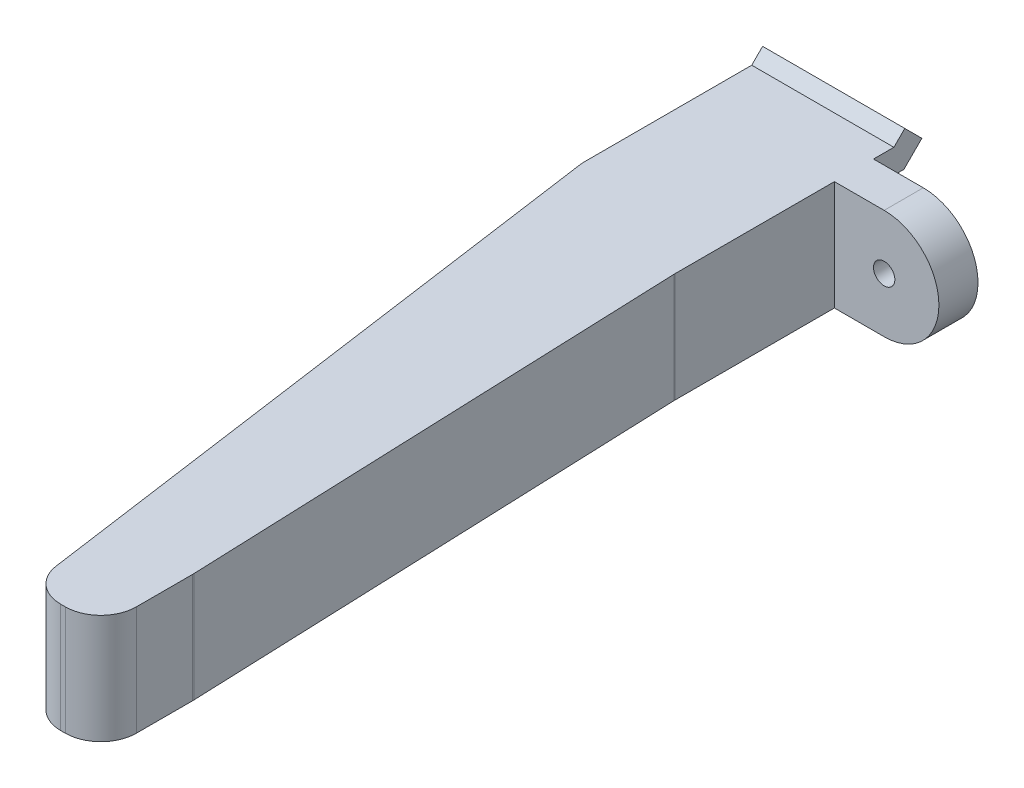
from build123d import *

# Parameters (mm, degrees)
SKETCH2_W           = 10
SKETCH2_H           = 14.768412439
BOSS_EXTRUDE1_DEPTH = 5
BOSS_EXTRUDE4_DEPTH = 10
SKETCH9_W           = 10
SKETCH9_H           = 3.18
SKETCH9_H_2         = 3.888412439
CUT_EXTRUDE3_DEPTH  = 5
BOSS_EXTRUDE5_DEPTH = 7.7
SKETCH12_R          = 0.75
BOSS_EXTRUDE7_DEPTH = 2.75
FILLET1_R           = 2.5


with BuildPart() as part:
    # Sketch2 → Boss-Extrude1 (new body)
    with BuildSketch(Plane.XY):
        with Locations((0, 1.566049366)):
            Rectangle(SKETCH2_W, SKETCH2_H)
    extrude(amount=BOSS_EXTRUDE1_DEPTH)

    # Sketch8 → Boss-Extrude4 (add)
    with BuildSketch(Plane.ZY.offset(5)):
        Polygon((-0.15, 5.770255585), (0, 5.770255585), (0, 4.070255585), (-0.15, 4.070255585), (-2.137867966, 4.070255585), (-3.402081528, 5.334469147), (-2.2, 6.536550675), (-1.43370491, 5.770255585), align=None)
        Polygon((-0.15, -1.929744415), (0, -1.929744415), (0, -0.229744415), (-0.15, -0.229744415), (-1.43370491, -0.229744415), (-2.2, 0.536550675), (-3.402081528, -0.665530853), (-2.137867966, -1.929744415), align=None)
    extrude(amount=-BOSS_EXTRUDE4_DEPTH)

    # Sketch9 → Cut-Extrude3 (cut)
    with BuildSketch(Plane(origin=(0, 0, 0), x_dir=(-1, 0, 0), z_dir=(0, 0, -1))):
        with Locations((0, 7.360255585)):
            Rectangle(SKETCH9_W, SKETCH9_H)
        with Locations((0, -3.873950635)):
            Rectangle(SKETCH9_W, SKETCH9_H_2)
    extrude(amount=-CUT_EXTRUDE3_DEPTH, mode=Mode.SUBTRACT)

    # Sketch10 → Boss-Extrude5 (add)
    with BuildSketch(Plane(origin=(0, 5.770255585, 0), x_dir=(1, 0, 0), z_dir=(0, 1, 0))):
        Polygon((-5, -5), (-5, -10.5), (1.352445729, -55.7), (6.352445729, -55.7), (6.352445729, -49.2), (5, -14), (5, -5), align=None)
    extrude(amount=-BOSS_EXTRUDE5_DEPTH)

    # Sketch12 → Boss-Extrude7 (add)
    with BuildSketch(Plane.XY):
        with BuildLine():
            Line((5, 5.770255585), (8.5, 5.770255585))
            ThreePointArc((8.5, 5.770255585), (12.35, 1.920255585), (8.5, -1.929744415))
            Line((8.5, -1.929744415), (5, -1.929744415))
            Line((5, -1.929744415), (5, 5.770255585))
        make_face()
        with Locations((8.5, 1.920255585)):
            Circle(SKETCH12_R, mode=Mode.SUBTRACT)
    extrude(amount=BOSS_EXTRUDE7_DEPTH)

    # Fillet1
    fillet1_edges = [part.edges().sort_by_distance(p)[0] for p in [
        (6.352445729, 1.920255585, 49.2),
        (5, 1.920255585, 14),
        (1.352445729, 1.920255585, 55.7),
        (6.352445729, 1.920255585, 55.7),
    ]]
    fillet(fillet1_edges, radius=FILLET1_R)


solid = part.part
